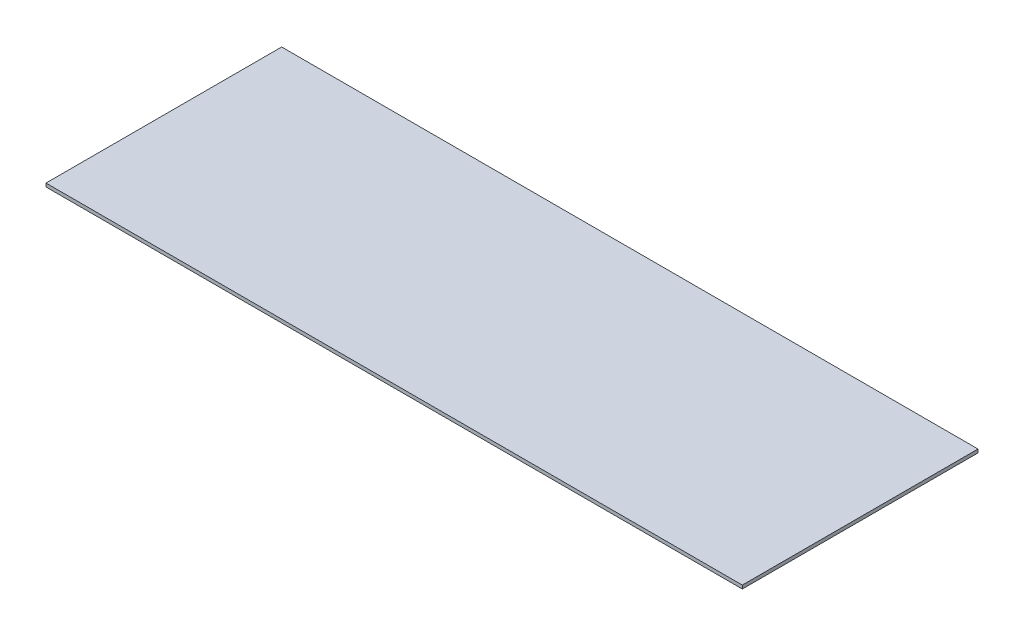
from build123d import *

# Parameters (mm, degrees)
SKETCH1_W      = 325
SKETCH1_H      = 110
EXTRUDE1_DEPTH = 1.6


with BuildPart() as part:
    # Sketch1 → Extrude1 (new body)
    with BuildSketch(Plane(origin=(0, 0, 0), x_dir=(1, 0, 0), z_dir=(0, 1, 0))):
        with Locations((65.373304473, -53.958472608)):
            Rectangle(SKETCH1_W, SKETCH1_H)
    extrude(amount=EXTRUDE1_DEPTH)


solid = part.part
